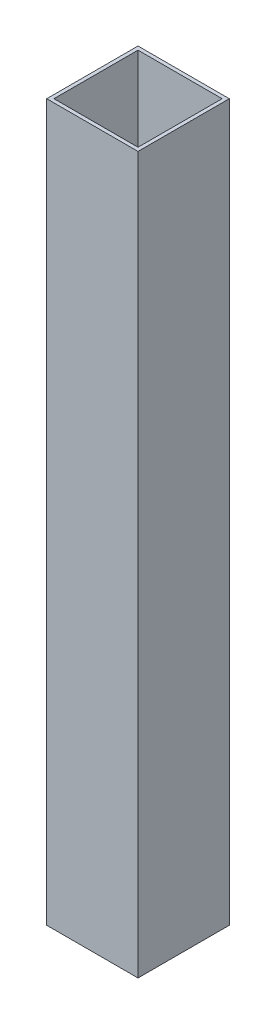
from build123d import *

# Parameters (mm, degrees)
SKETCH1_W           = 25.4
SKETCH1_H           = 25.4
SKETCH1_W_2         = 23.4
SKETCH1_H_2         = 23.4
BOSS_EXTRUDE1_DEPTH = 199.2


with BuildPart() as part:
    # Sketch1 → Boss-Extrude1 (new body)
    with BuildSketch(Plane(origin=(0, 0, 0), x_dir=(1, 0, 0), z_dir=(0, 1, 0))):
        with Locations((12.7, -12.7)):
            Rectangle(SKETCH1_W, SKETCH1_H)
        with Locations((12.7, -12.7)):
            Rectangle(SKETCH1_W_2, SKETCH1_H_2, mode=Mode.SUBTRACT)
    extrude(amount=BOSS_EXTRUDE1_DEPTH)


solid = part.part
